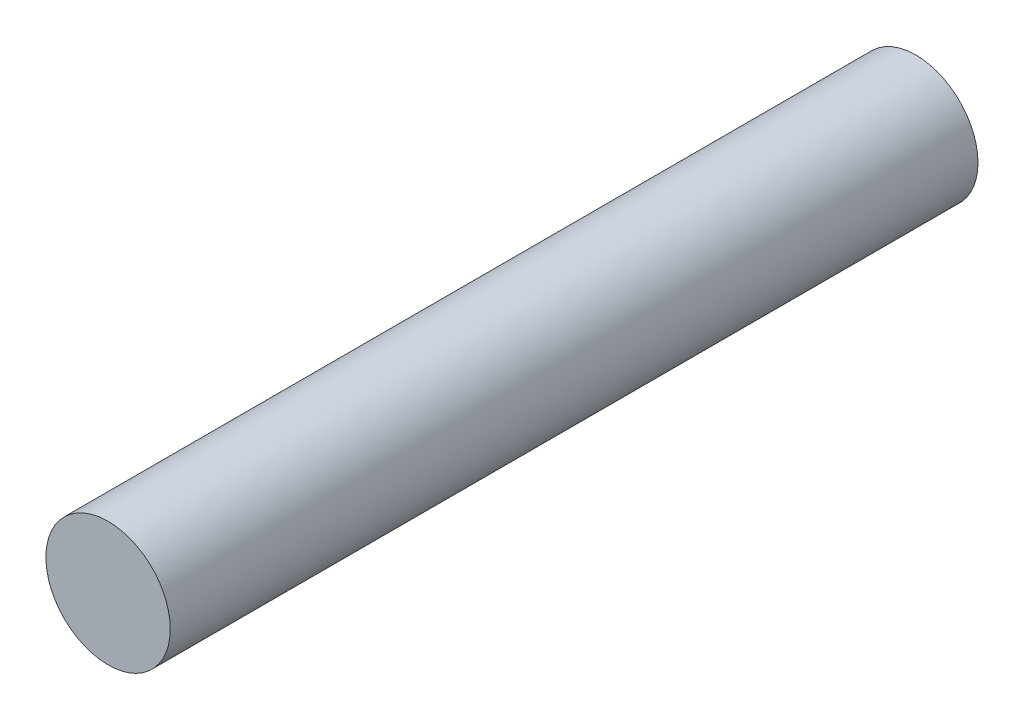
from build123d import *

# Parameters (mm, degrees)
SKETCH2_R      = 1.1303
EXTRUDE1_DEPTH = 14.6812


with BuildPart() as part:
    # Sketch2 → Extrude1 (new body)
    with BuildSketch(Plane.XY):
        Circle(SKETCH2_R)
    extrude(amount=EXTRUDE1_DEPTH)


solid = part.part
